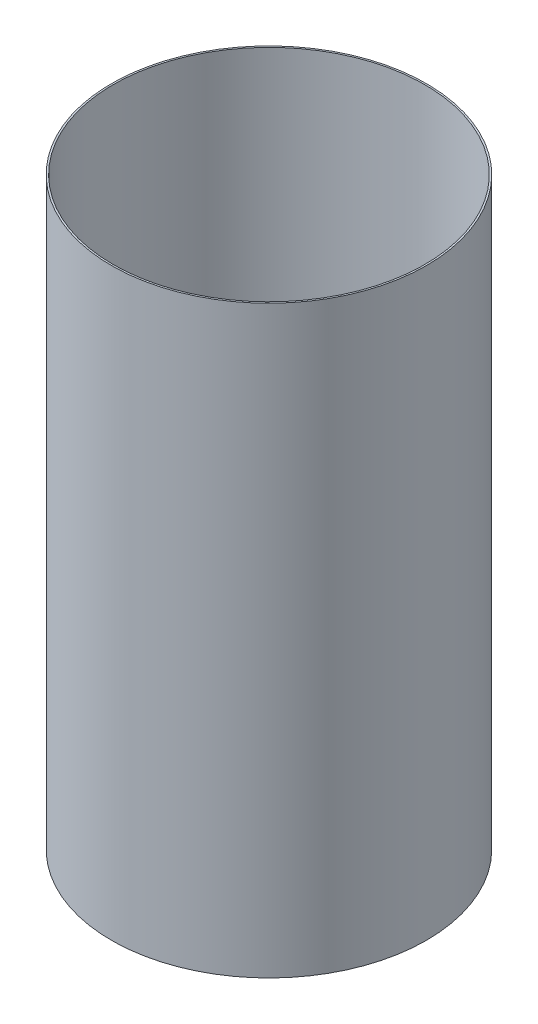
from build123d import *

# Parameters (mm, degrees)
SKETCH1_R           = 51.3588
SKETCH1_R_2         = 50.8
EXTRUDE_THIN1_DEPTH = 190.5


with BuildPart() as part:
    # Sketch1 → Extrude-Thin1 (new body)
    with BuildSketch(Plane(origin=(0, 0, 0), x_dir=(1, 0, 0), z_dir=(0, 1, 0))):
        Circle(SKETCH1_R)
        Circle(SKETCH1_R_2, mode=Mode.SUBTRACT)
    extrude(amount=EXTRUDE_THIN1_DEPTH)


solid = part.part
